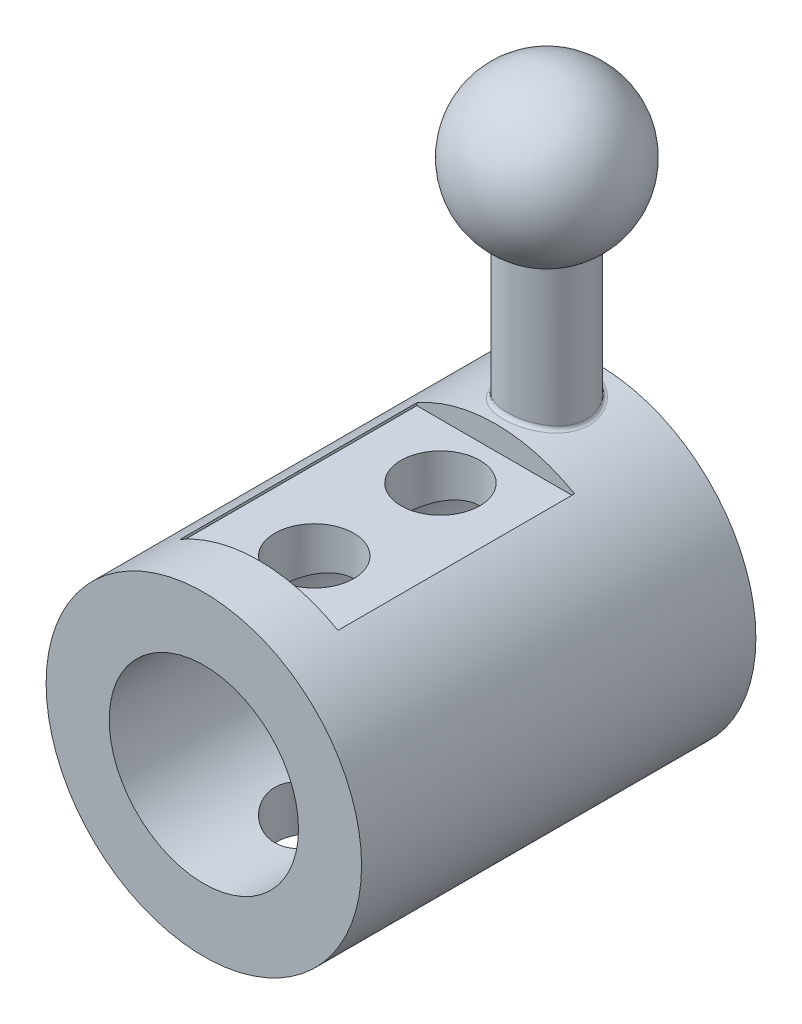
from build123d import *

# Parameters (mm, degrees)
SKETCH1_R           = 10
SKETCH1_R_2         = 6
BOSS_EXTRUDE1_DEPTH = 25
BOSS_EXTRUDE2_START = -0.317539
SKETCH2_R           = 2.5
BOSS_EXTRUDE2_DEPTH = 10.317539
FILLET1_R           = 0.25
SKETCH5_R           = 2.5
CUT_EXTRUDE1_DEPTH  = 34.541019826
SKETCH6_W           = 10
SKETCH6_H           = 15
CUT_EXTRUDE3_DEPTH  = 1.5


with BuildPart() as part:
    # Sketch1 → Boss-Extrude1 (new body)
    with BuildSketch(Plane.XY):
        Circle(SKETCH1_R)
        Circle(SKETCH1_R_2, mode=Mode.SUBTRACT)
    extrude(amount=BOSS_EXTRUDE1_DEPTH)


with BuildPart() as boss_extrude2_tool:
    # Sketch2 → Boss-Extrude2 (new body)
    with BuildSketch(Plane(origin=(0, 10, 0), x_dir=(1, 0, 0), z_dir=(0, 1, 0)).offset(BOSS_EXTRUDE2_START)):
        with Locations(Location((0, -3.25, 0), (0, 0, 90))):
            Circle(SKETCH2_R)
    extrude(amount=BOSS_EXTRUDE2_DEPTH)


with BuildPart() as part_1:
    add(part.part)


with BuildPart() as part_2:
    # Boss-Extrude2: joined with boss_extrude2_tool
    add(part_1.part.fuse(boss_extrude2_tool.part, tol=0.00001))

    # Fillet1
    fillet1_edges = [part_2.edges().sort_by_distance(p)[0] for p in [
        (-2e-09, 9.999999993, 5.750000022),
    ]]
    fillet(fillet1_edges, radius=FILLET1_R)

    # Sketch5 → Cut-Extrude1 (cut, through all)
    with BuildSketch(Plane(origin=(0, 10, 0), x_dir=(1, 0, 0), z_dir=(0, 1, 0))):
        with Locations(Location((0, -10, 0), (0, 0, 270))):
            Circle(SKETCH5_R)
        with Locations(Location((0, -18, 0), (0, 0, 270))):
            Circle(SKETCH5_R)
    extrude(amount=-CUT_EXTRUDE1_DEPTH, mode=Mode.SUBTRACT)

    # Sketch6 → Cut-Extrude3 (cut)
    with BuildSketch(Plane(origin=(0, 10, 0), x_dir=(1, 0, 0), z_dir=(0, 1, 0))):
        with Locations((0, -14)):
            Rectangle(SKETCH6_W, SKETCH6_H)
    cut_extrude3 = extrude(amount=-CUT_EXTRUDE3_DEPTH, mode=Mode.SUBTRACT)

    # Mirror1: Cut-Extrude3 across plane
    add(cut_extrude3.mirror(Plane.ZX), mode=Mode.SUBTRACT)

    # Sketch4 → Revolve1 (revolve)
    with BuildSketch(Plane(origin=(0, 0, 3.25), x_dir=(-1, 0, 0), z_dir=(0, 0, -1))):
        with BuildLine():
            Line((0, 18), (0, 28))
            ThreePointArc((0, 28), (-5, 23), (0, 18))
        make_face()
    revolve(axis=Axis((0, 18, 3.25), (0, 1, 0)))


solid = part_2.part
